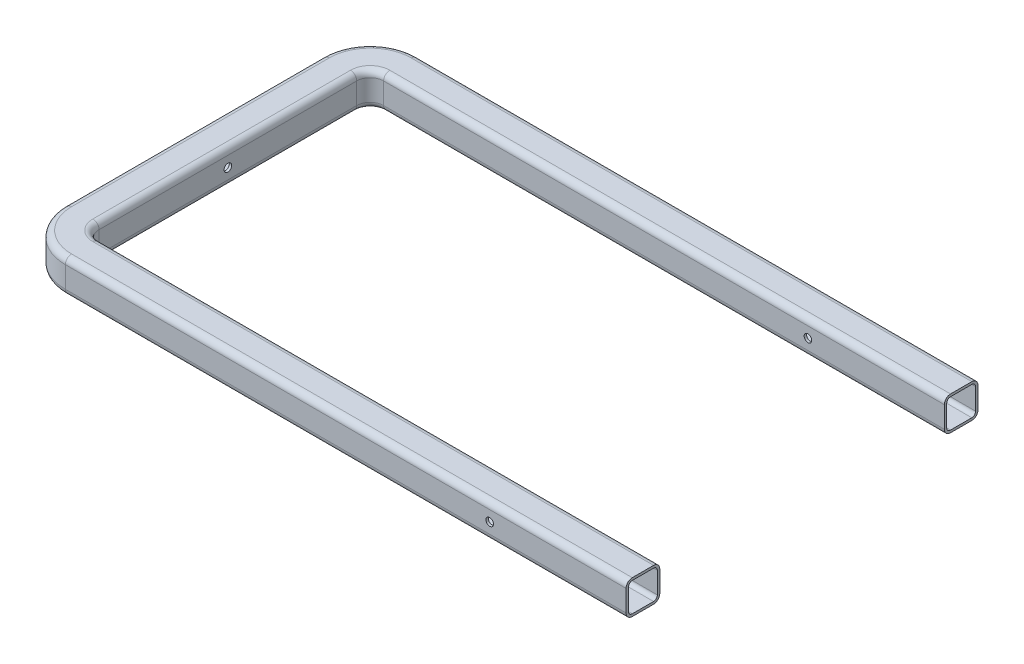
from build123d import *

# Parameters (mm, degrees)
SKETCH3_R               = 5
CUT_EXTRUDE1_DEPTH      = 23.2250001
CUT_EXTRUDE1_DEPTH_BACK = 443.2250001
SKETCH6_R               = 5
CUT_EXTRUDE2_DEPTH      = 803.225


with BuildPart() as part:
    # Sweep-Thin1: sweep along a path in Sketch1
    with BuildLine(Plane(origin=(0, 0, 0), x_dir=(1, 0, 0), z_dir=(0, 1, 0))) as sweep_thin1_path:
        Line((130, 0), (0, 0))
        Line((0, 0), (-610, 0))
        ThreePointArc((-610, 0), (-638.284271247, 11.715728753), (-650, 40))
        Line((-650, 40), (-650, 380))
        ThreePointArc((-650, 380), (-638.284271247, 408.284271247), (-610, 420))
        Line((-610, 420), (0, 420))
        Line((0, 420), (130, 420))
    # Sketch2 → Sweep-Thin1 (sweep)
    with BuildSketch(Plane(origin=(0, 0, 0), x_dir=(0, 0, -1), z_dir=(1, 0, 0))):
        with BuildLine():
            Line((14.05, 22.225), (-14.05, 22.225))
            ThreePointArc((-14.05, 22.225), (-19.830597936, 19.830597936), (-22.225, 14.05))
            Line((-22.225, 14.05), (-22.225, -14.05))
            ThreePointArc((-22.225, -14.05), (-19.830597936, -19.830597936), (-14.05, -22.225))
            Line((-14.05, -22.225), (14.05, -22.225))
            ThreePointArc((14.05, -22.225), (19.830597936, -19.830597936), (22.225, -14.05))
            Line((22.225, -14.05), (22.225, 14.05))
            ThreePointArc((22.225, 14.05), (19.830597936, 19.830597936), (14.05, 22.225))
        make_face()
        with BuildLine():
            Line((14.05, 19.05), (-14.05, 19.05))
            ThreePointArc((-14.05, 19.05), (-17.585533906, 17.585533906), (-19.05, 14.05))
            Line((-19.05, 14.05), (-19.05, -14.05))
            ThreePointArc((-19.05, -14.05), (-17.585533906, -17.585533906), (-14.05, -19.05))
            Line((-14.05, -19.05), (14.05, -19.05))
            ThreePointArc((14.05, -19.05), (17.585533906, -17.585533906), (19.05, -14.05))
            Line((19.05, -14.05), (19.05, 14.05))
            ThreePointArc((19.05, 14.05), (17.585533906, 17.585533906), (14.05, 19.05))
        make_face(mode=Mode.SUBTRACT)
    sweep(path=sweep_thin1_path.line)

    # Sketch3 → Cut-Extrude1 (cut, two sides)
    with BuildSketch(Plane.XY) as cut_extrude1_sk:
        with Locations((-50, 0)):
            Circle(SKETCH3_R)
    extrude(amount=CUT_EXTRUDE1_DEPTH, mode=Mode.SUBTRACT)
    extrude(cut_extrude1_sk.sketch, amount=-CUT_EXTRUDE1_DEPTH_BACK, mode=Mode.SUBTRACT)

    # Sketch6 → Cut-Extrude2 (cut, through all)
    with BuildSketch(Plane.ZY.offset(672.225)):
        with Locations((-210, 0)):
            Circle(SKETCH6_R)
    extrude(amount=-CUT_EXTRUDE2_DEPTH, mode=Mode.SUBTRACT)


solid = part.part
